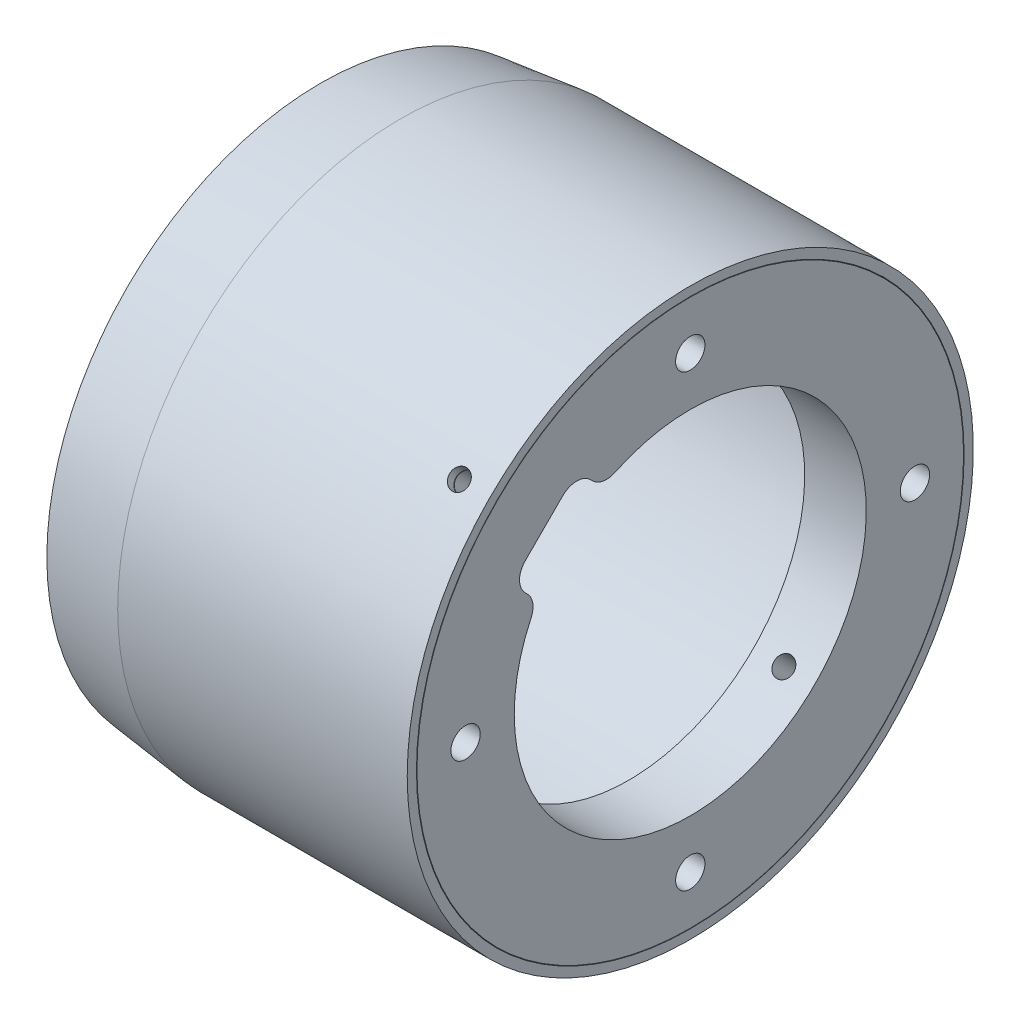
from build123d import *

# Parameters (mm, degrees)
SKETCH2_W          = 10
SKETCH2_H          = 15.795
SKETCH3_R          = 2.38125
CUT_EXTRUDE1_DEPTH = 61
SKETCH4_R          = 1.5875
CUT_EXTRUDE2_DEPTH = 17.419131
CIRPATTERN1_COUNT  = 4
CUT_EXTRUDE3_DEPTH = 10
FILLET1_R          = 3.2


with BuildPart() as part:
    # Sketch1 → Revolve1 (revolve)
    with BuildSketch(Plane.XY):
        Polygon((13, 45.95), (60, 45.95), (60, 44.45), (0, 44.45), align=None)
    revolve(axis=Axis((0, 0, 0), (1, 0, 0)))


with BuildPart() as body_2:
    # Sketch2 → Revolve2 (revolve)
    with BuildSketch(Plane.XY):
        with Locations((55, 36.4725)):
            Rectangle(SKETCH2_W, SKETCH2_H)
    revolve(axis=Axis((0, 0, 0), (1, 0, 0)))

    # Sketch3 → Cut-Extrude1 (cut, through all)
    with BuildSketch(Plane(origin=(60, 0, 0), x_dir=(0, 0, -1), z_dir=(1, 0, 0))):
        with Locations((-36.4725, 0)):
            Circle(SKETCH3_R)
        with Locations((0, 36.4725)):
            Circle(SKETCH3_R)
        with Locations((36.4725, 0)):
            Circle(SKETCH3_R)
        with Locations((0, -36.4725)):
            Circle(SKETCH3_R)
    extrude(amount=-CUT_EXTRUDE1_DEPTH, mode=Mode.SUBTRACT)


with BuildPart() as cut_extrude2_tool:
    # Sketch4 → Cut-Extrude2 (new body)
    with BuildSketch(Plane(origin=(0, 32.491556596, 32.491556596), x_dir=(-1, 0, 0), z_dir=(0, 0.707106781, 0.707106781))):
        with Locations((-55, 0)):
            Circle(SKETCH4_R)
    cut_extrude2 = extrude(amount=-CUT_EXTRUDE2_DEPTH)


with BuildPart() as part_1:
    add(part.part)

    # Cut-Extrude2: cut by cut_extrude2_tool
    add(cut_extrude2_tool.part, mode=Mode.SUBTRACT)


with BuildPart() as body_2_1:
    add(body_2.part)

    # Cut-Extrude2: cut by cut_extrude2_tool
    add(cut_extrude2_tool.part, mode=Mode.SUBTRACT)


with BuildPart() as cirpattern1_tool:
    # CirPattern1: Cut-Extrude2 ×4 about axis
    cirpattern1_axis = Axis((60, 0, 0), (-1, 0, 0))
    for i in range(1, CIRPATTERN1_COUNT):
        add(cut_extrude2.rotate(cirpattern1_axis, i * 360 / CIRPATTERN1_COUNT))


with BuildPart() as part_2:
    add(part_1.part)

    # CirPattern1: cut by cirpattern1_tool
    add(cirpattern1_tool.part, mode=Mode.SUBTRACT)


with BuildPart() as body_2_2:
    add(body_2_1.part)

    # CirPattern1: cut by cirpattern1_tool
    add(cirpattern1_tool.part, mode=Mode.SUBTRACT)

    # Sketch5 → Cut-Extrude3 (cut)
    with BuildSketch(Plane(origin=(60, 0, 0), x_dir=(0, 0, -1), z_dir=(1, 0, 0))):
        Polygon((-29.044411037, 18.437809319), (-18.437809319, 29.044411037), (-11.366741508, 21.973343225), (-21.973343225, 11.366741508), align=None)
    extrude(amount=-CUT_EXTRUDE3_DEPTH, mode=Mode.SUBTRACT)

    # Fillet1
    fillet1_edges = [body_2_2.edges().sort_by_distance(p)[0] for p in [
        (55, 14.193886438, 24.800488156),
        (55, 24.800488156, 14.193886438),
        (55, 29.044411037, 18.437809319),
        (55, 18.437809319, 29.044411037),
    ]]
    fillet(fillet1_edges, radius=FILLET1_R)


solid = Compound([part_2.part, body_2_2.part])
